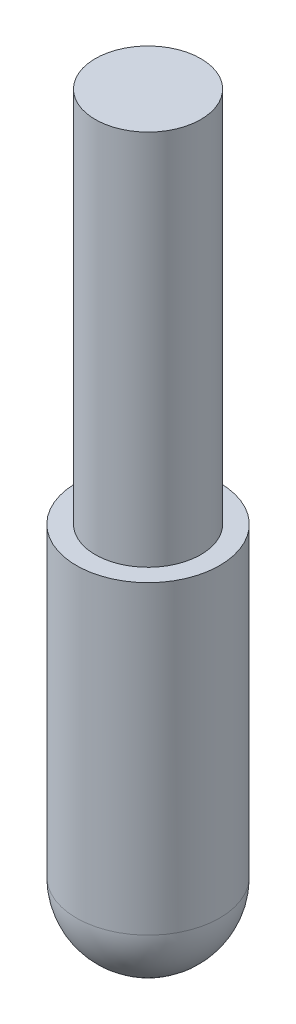
from build123d import *


with BuildPart() as part:
    # Sketch1 → Revolve1 (revolve)
    with BuildSketch(Plane(origin=(0, 0, 0), x_dir=(0, 0, -1), z_dir=(1, 0, 0))):
        with BuildLine():
            Line((0, 25), (3.5, 25))
            Line((3.5, 25), (3.5, 0))
            Line((3.5, 0), (4.75, 0))
            Line((4.75, 0), (4.75, -20.25))
            ThreePointArc((4.75, -20.25), (3.358757211, -23.608757211), (0, -25))
            Line((0, -25), (0, 25))
        make_face()
    revolve(axis=Axis((0, -25, 0), (0, 1, 0)))


solid = part.part
